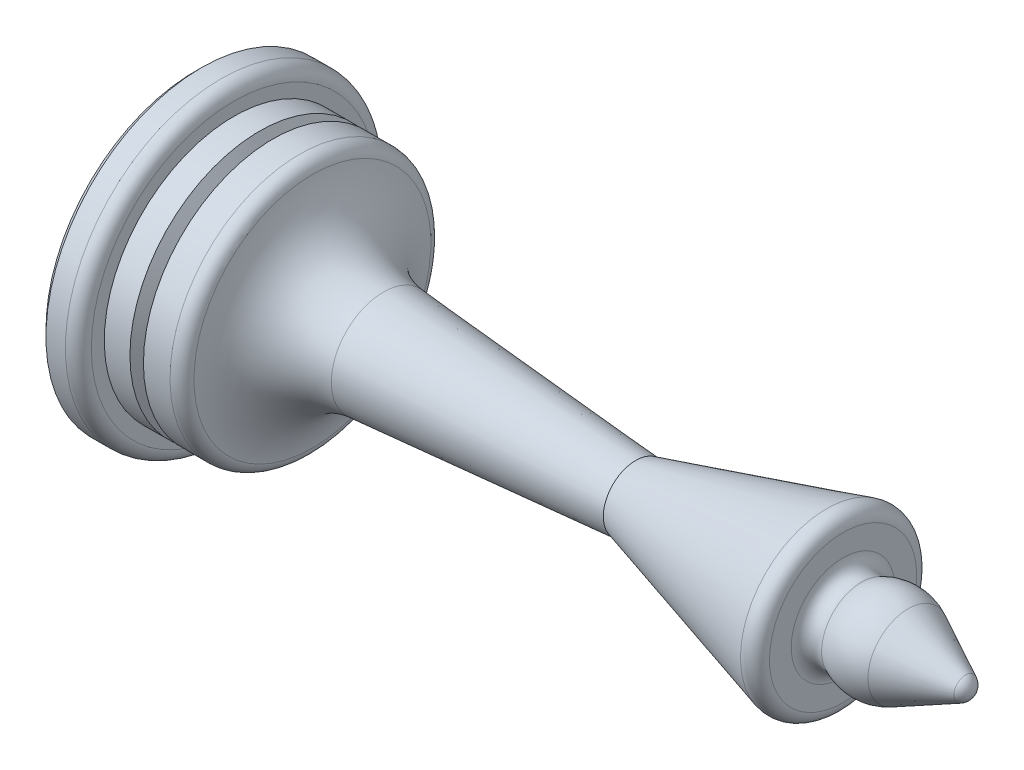
from build123d import *

# Parameters (mm, degrees)
SKETCH3_R          = 6
CUT_EXTRUDE1_DEPTH = 5
FILLET1_R          = 1


with BuildPart() as part:
    # Sketch1 → Revolve1 (revolve)
    with BuildSketch(Plane.XY, mode=Mode.PRIVATE) as revolve1_sk:
        with BuildLine():
            Line((0, 0), (0, 11.5))
            Line((0, 11.5), (0.5, 12))
            Line((0.5, 12), (2, 12))
            ThreePointArc((2, 12), (2.707106781, 11.707106781), (3, 11))
            Line((3, 11), (3, 10))
            Line((3, 10), (8.07179677, 10))
            ThreePointArc((8.07179677, 10), (8.72645044, 9.755928946), (9.061540088, 9.142857143))
            ThreePointArc((9.061540088, 9.142857143), (10.898592422, 5.620678605), (14.533485708, 4.018163792))
            Line((14.533485708, 4.018163792), (30.453982854, 2.776548475))
            Line((30.453982854, 2.776548475), (34, 2.5))
            Line((34, 2.5), (37.423942034, 3.462983697))
            Line((37.423942034, 3.462983697), (50, 7))
            Line((50, 7), (50, 4))
            ThreePointArc((50, 4), (50.474268888, 3.149349192), (51.447213595, 3.105572809))
            ThreePointArc((51.447213595, 3.105572809), (53.236067977, 3.527864045), (55.024922359, 3.105572809))
            Line((55.024922359, 3.105572809), (59.447213595, 0.894427191))
            ThreePointArc((59.447213595, 0.894427191), (59.850650808, 0.525731112), (60, 0))
            Line((60, 0), (0, 0))
        make_face()
    revolve(revolve1_sk.sketch.rotate(Axis((0, 0, 0), (1, 0, 0)), 180), axis=Axis((0, 0, 0), (1, 0, 0)))  # turned: the seam where the file's is

    # Sketch2 → Cut-Revolve1 (revolve, cut)
    with BuildSketch(Plane.XY, mode=Mode.PRIVATE) as cut_revolve1_sk:
        Polygon((4.979432949, 10), (5.5, 9), (6.020567051, 10), align=None)
    revolve(cut_revolve1_sk.sketch.rotate(Axis((0, 0, 0), (1, 0, 0)), 180), axis=Axis((0, 0, 0), (1, 0, 0)), mode=Mode.SUBTRACT)  # turned: the seam where the file's is

    # Sketch3 → Cut-Extrude1 (cut)
    with BuildSketch(Plane.ZY):
        with Locations(Location((0, 0, 0), (0, 0, 270))):  # turned: the seam where the file's is
            Circle(SKETCH3_R)
    extrude(amount=-CUT_EXTRUDE1_DEPTH, mode=Mode.SUBTRACT)

    # Fillet1
    fillet1_edges = [part.edges().sort_by_distance(p)[0] for p in [
        (50, 7, 0),
    ]]
    fillet(fillet1_edges, radius=FILLET1_R)


solid = part.part
